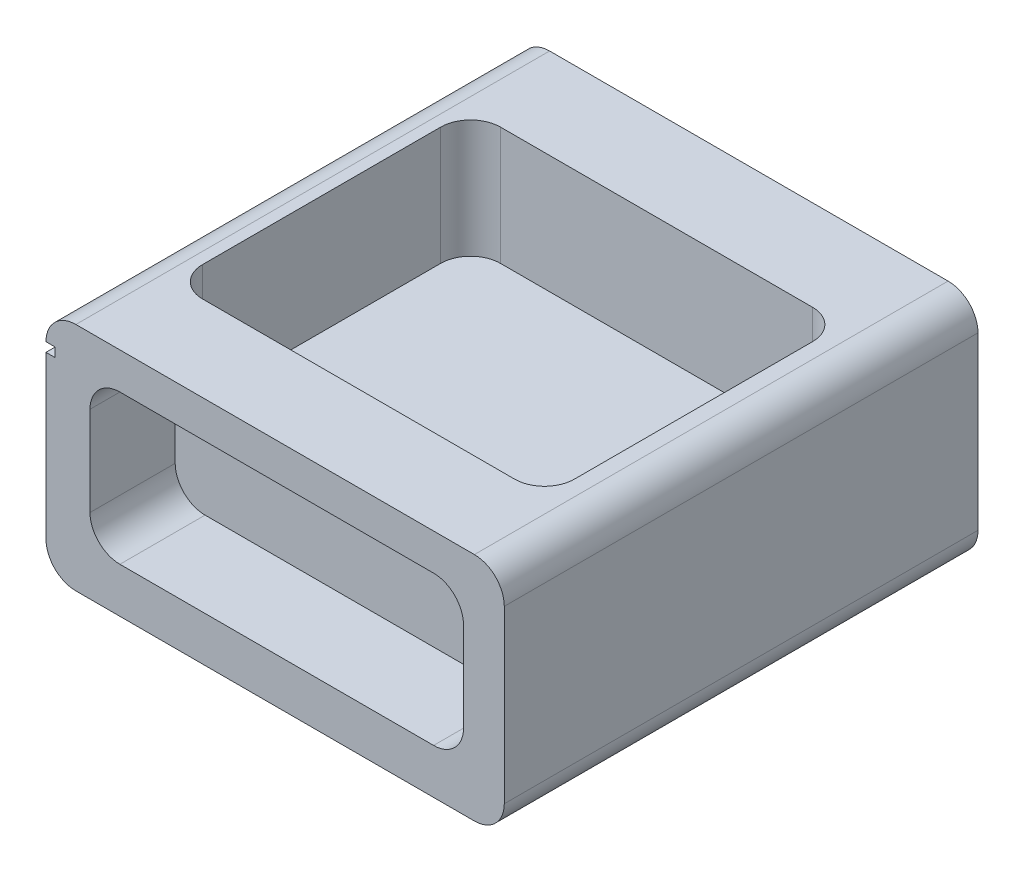
from build123d import *

# Parameters (mm, degrees)
BOSS_EXTRUDE1_DEPTH = 14.478
BOSS_EXTRUDE2_DEPTH = 66.04
SKETCH3_W           = 80.518
SKETCH3_H           = 1.477027813
BOSS_EXTRUDE3_DEPTH = 1.524
SKETCH4_W           = 80.518
SKETCH4_H           = 1.559652671
CUT_EXTRUDE1_DEPTH  = 1.524
CUT_EXTRUDE3_DEPTH  = 14.478
CUT_EXTRUDE6_DEPTH  = 20.066


with BuildPart() as part:
    # Sketch1 → Boss-Extrude1 (new body)
    with BuildSketch(Plane.XY):
        with BuildLine():
            Line((-72.819716666, 29.55445925), (-5.08, 29.55445925))
            ThreePointArc((-5.08, 29.55445925), (-1.487897552, 28.066561699), (0, 24.47445925))
            Line((0, 24.47445925), (0, -4.589051483))
            ThreePointArc((0, -4.589051483), (-1.487897552, -8.181153932), (-5.08, -9.669051483))
            Line((-5.08, -9.669051483), (-72.819716666, -9.669051483))
            ThreePointArc((-72.819716666, -9.669051483), (-76.411819114, -8.181153932), (-77.899716666, -4.589051483))
            Line((-77.899716666, -4.589051483), (-77.899716666, 24.47445925))
            ThreePointArc((-77.899716666, 24.47445925), (-76.411819114, 28.066561699), (-72.819716666, 29.55445925))
        make_face()
        with BuildLine():
            Line((-65.339884386, 23.351671506), (-12.012527478, 23.351671506))
            ThreePointArc((-12.012527478, 23.351671506), (-8.42042503, 21.863773955), (-6.932527478, 18.271671506))
            Line((-6.932527478, 18.271671506), (-6.932527478, 3.07321573))
            ThreePointArc((-6.932527478, 3.07321573), (-8.42042503, -0.518886719), (-12.012527478, -2.00678427))
            Line((-12.012527478, -2.00678427), (-65.339884386, -2.00678427))
            ThreePointArc((-65.339884386, -2.00678427), (-68.931986835, -0.518886719), (-70.419884386, 3.07321573))
            Line((-70.419884386, 3.07321573), (-70.419884386, 18.271671506))
            ThreePointArc((-70.419884386, 18.271671506), (-68.931986835, 21.863773955), (-65.339884386, 23.351671506))
        make_face(mode=Mode.SUBTRACT)
    extrude(amount=BOSS_EXTRUDE1_DEPTH)

    # Sketch2 → Boss-Extrude2 (add)
    with BuildSketch(Plane(origin=(0, 0, 0), x_dir=(-1, 0, 0), z_dir=(0, 0, -1))):
        with BuildLine():
            Line((5.08, 29.55445925), (72.819716666, 29.55445925))
            ThreePointArc((72.819716666, 29.55445925), (76.411819114, 28.066561699), (77.899716666, 24.47445925))
            Line((77.899716666, 24.47445925), (77.899716666, -4.589051483))
            ThreePointArc((77.899716666, -4.589051483), (76.411819114, -8.181153932), (72.819716666, -9.669051483))
            Line((72.819716666, -9.669051483), (5.08, -9.669051483))
            ThreePointArc((5.08, -9.669051483), (1.487897552, -8.181153932), (0, -4.589051483))
            Line((0, -4.589051483), (0, 24.47445925))
            ThreePointArc((0, 24.47445925), (1.487897552, 28.066561699), (5.08, 29.55445925))
        make_face()
    extrude(amount=BOSS_EXTRUDE2_DEPTH)

    # Sketch3 → Boss-Extrude3 (add)
    with BuildSketch(Plane.ZY.offset(77.899716666)):
        with Locations((-25.781, 23.735945344)):
            Rectangle(SKETCH3_W, SKETCH3_H)
    extrude(amount=-BOSS_EXTRUDE3_DEPTH)

    # Sketch4 → Cut-Extrude1 (cut)
    with BuildSketch(Plane.ZY.offset(77.899716666)):
        with Locations((-25.781, 23.694632915)):
            Rectangle(SKETCH4_W, SKETCH4_H)
    extrude(amount=-CUT_EXTRUDE1_DEPTH, mode=Mode.SUBTRACT)

    # Sketch8 → Cut-Extrude3 (cut)
    with BuildSketch(Plane(origin=(0, 0.399775278, -66.04), x_dir=(-1, 0, 0), z_dir=(0, 0, -1))):
        with BuildLine():
            Line((13.813270209, 22.173227648), (64.646012904, 22.173227648))
            ThreePointArc((64.646012904, 22.173227648), (68.238115352, 20.685330097), (69.726012904, 17.093227648))
            Line((69.726012904, 17.093227648), (69.726012904, 3.751436885))
            ThreePointArc((69.726012904, 3.751436885), (68.238115352, 0.159334436), (64.646012904, -1.328563115))
            Line((64.646012904, -1.328563115), (13.813270209, -1.328563115))
            ThreePointArc((13.813270209, -1.328563115), (10.22116776, 0.159334436), (8.733270209, 3.751436885))
            Line((8.733270209, 3.751436885), (8.733270209, 17.093227648))
            ThreePointArc((8.733270209, 17.093227648), (10.22116776, 20.685330097), (13.813270209, 22.173227648))
        make_face()
    extrude(amount=-CUT_EXTRUDE3_DEPTH, mode=Mode.SUBTRACT)

    # Sketch10 → Cut-Extrude6 (cut)
    with BuildSketch(Plane(origin=(0, 29.55445925, 6.792687041), x_dir=(1, 0, 0), z_dir=(0, 1, 0))):
        with BuildLine():
            Line((-65.795513853, 57.457874707), (-12.761974665, 57.457874707))
            ThreePointArc((-12.761974665, 57.457874707), (-9.169872217, 55.969977155), (-7.681974665, 52.377874707))
            Line((-7.681974665, 52.377874707), (-7.681974665, 11.913822303))
            ThreePointArc((-7.681974665, 11.913822303), (-9.169872217, 8.321719854), (-12.761974665, 6.833822303))
            Line((-12.761974665, 6.833822303), (-65.795513853, 6.833822303))
            ThreePointArc((-65.795513853, 6.833822303), (-69.387616301, 8.321719854), (-70.875513853, 11.913822303))
            Line((-70.875513853, 11.913822303), (-70.875513853, 52.377874707))
            ThreePointArc((-70.875513853, 52.377874707), (-69.387616301, 55.969977155), (-65.795513853, 57.457874707))
        make_face()
    extrude(amount=-CUT_EXTRUDE6_DEPTH, mode=Mode.SUBTRACT)


solid = part.part
